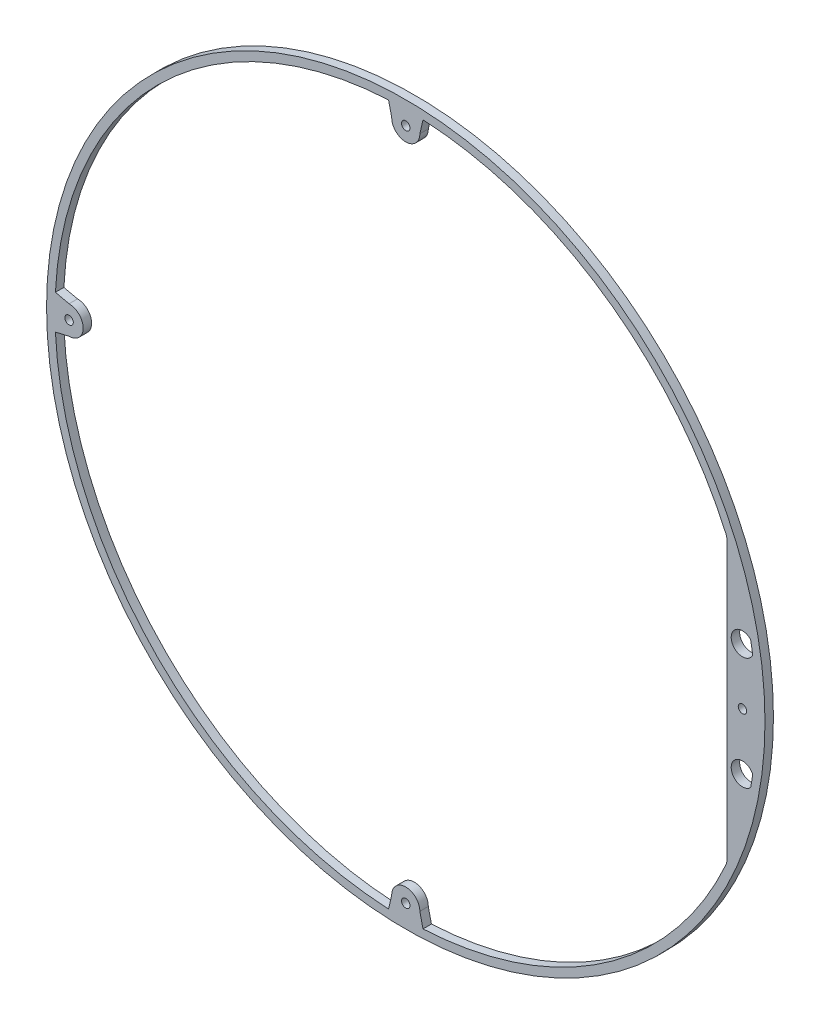
from build123d import *

# Parameters (mm, degrees)
SKETCH1_R           = 127.525
SKETCH1_R_2         = 124.525
BOSS_EXTRUDE1_DEPTH = 3
SKETCH2_R           = 1.5
BOSS_EXTRUDE2_DEPTH = 3
BOSS_EXTRUDE3_DEPTH = 3
FILLET1_R           = 5


with BuildPart() as part:
    # Sketch1 → Boss-Extrude1 (new body)
    with BuildSketch(Plane.XY):
        Circle(SKETCH1_R)
        Circle(SKETCH1_R_2, mode=Mode.SUBTRACT)
    extrude(amount=BOSS_EXTRUDE1_DEPTH)

    # Sketch2 → Boss-Extrude2 (add)
    with BuildSketch(Plane.XY.offset(3)):
        with BuildLine():
            Line((-6.110237311, 124.375), (-5, 119.525))
            ThreePointArc((-5, 119.525), (0, 114.525), (5, 119.525))
            Line((5, 119.525), (6.110237311, 124.375))
            ThreePointArc((6.110237311, 124.375), (0, 124.525), (-6.110237311, 124.375))
        make_face()
        with Locations((0, 119.525)):
            Circle(SKETCH2_R, mode=Mode.SUBTRACT)
        with BuildLine():
            Line((-119.525, 5), (-124.375, 6.110237311))
            ThreePointArc((-124.375, 6.110237311), (-124.525, 0), (-124.375, -6.110237311))
            Line((-124.375, -6.110237311), (-119.525, -5))
            ThreePointArc((-119.525, -5), (-114.525, 0), (-119.525, 5))
        make_face()
        with Locations((-119.525, 0)):
            Circle(SKETCH2_R, mode=Mode.SUBTRACT)
        with BuildLine():
            Line((-5, -119.525), (-6.110237311, -124.375))
            ThreePointArc((-6.110237311, -124.375), (0, -124.525), (6.110237311, -124.375))
            Line((6.110237311, -124.375), (5, -119.525))
            ThreePointArc((5, -119.525), (0, -114.525), (-5, -119.525))
        make_face()
        with Locations((0, -119.525)):
            Circle(SKETCH2_R, mode=Mode.SUBTRACT)
        with BuildLine():
            ThreePointArc((124.525, 0), (124.487494352, 3.056039103), (124.375, 6.110237311))
            Line((124.375, 6.110237311), (119.525, 5))
            ThreePointArc((119.525, 5), (114.525, 0), (119.525, -5))
            Line((119.525, -5), (124.375, -6.110237311))
            ThreePointArc((124.375, -6.110237311), (124.487494352, -3.056039103), (124.525, 0))
        make_face()
        with Locations((119.525, 0)):
            Circle(SKETCH2_R, mode=Mode.SUBTRACT)
    extrude(amount=-BOSS_EXTRUDE2_DEPTH)

    # Sketch3 → Boss-Extrude3 (add)
    with BuildSketch(Plane.XY.offset(3)):
        with BuildLine():
            ThreePointArc((122.429089666, 22.750684136), (119.019917661, 36.616046004), (114.045936469, 50))
            Line((114.045936469, 50), (114.045936469, -50))
            ThreePointArc((114.045936469, -50), (119.019917661, -36.616046004), (122.429089666, -22.750684136))
            ThreePointArc((122.429089666, -22.750684136), (115.850579192, -21.580706086), (119.525, -16))
            Line((119.525, -16), (119.525, -5))
            ThreePointArc((119.525, -5), (114.525, 0), (119.525, 5))
            Line((119.525, 5), (119.525, 16))
            ThreePointArc((119.525, 16), (115.850579192, 21.580706086), (122.429089666, 22.750684136))
        make_face()
        with BuildLine():
            ThreePointArc((123.166362087, 18.34455983), (121.690437522, 16.636834774), (119.525, 16))
            Line((119.525, 16), (119.525, 5))
            Line((119.525, 5), (124.375, 6.110237311))
            ThreePointArc((124.375, 6.110237311), (123.921754135, 12.242323195), (123.166362087, 18.34455983))
        make_face()
        with BuildLine():
            Line((119.525, -5), (119.525, -16))
            ThreePointArc((119.525, -16), (121.690437522, -16.636834774), (123.166362087, -18.34455983))
            ThreePointArc((123.166362087, -18.34455983), (123.921754135, -12.242323195), (124.375, -6.110237311))
            Line((124.375, -6.110237311), (119.525, -5))
        make_face()
    extrude(amount=-BOSS_EXTRUDE3_DEPTH)

    # Fillet1
    fillet1_edges = [part.edges().sort_by_distance(p)[0] for p in [
        (114.045936469, 50, 1.5),
        (114.045936469, -50, 1.5),
    ]]
    fillet(fillet1_edges, radius=FILLET1_R)


solid = part.part
